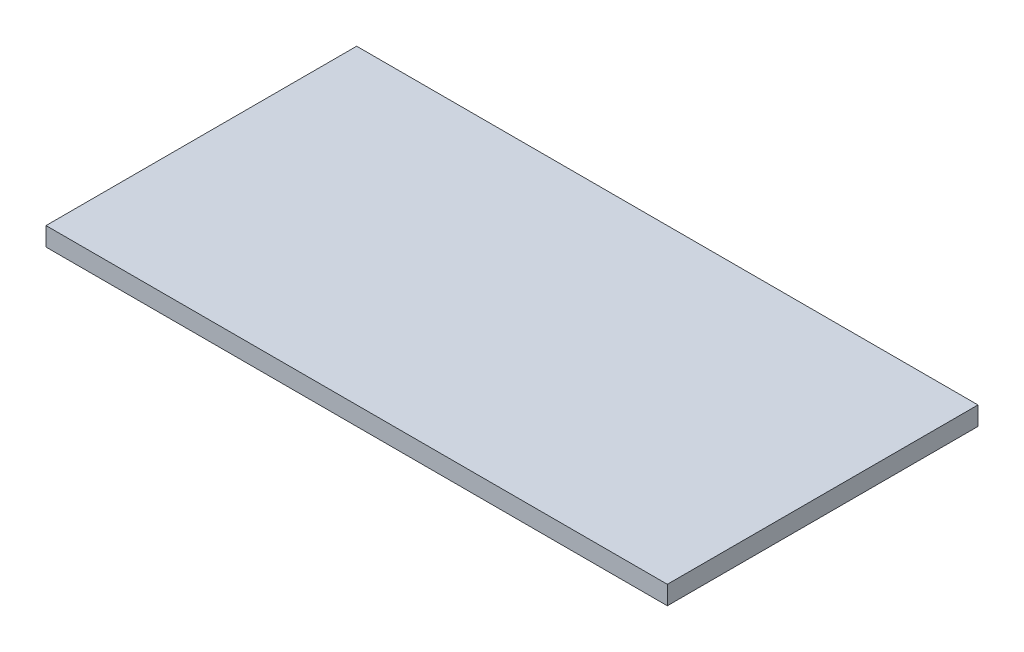
from build123d import *

# Parameters (mm, degrees)
SKETCH_1_W      = 600
SKETCH_1_H      = 300
EXTRUDE_1_DEPTH = 18


with BuildPart() as part:
    # Эскиз1 → Бобышка-Вытянуть1 (new body)
    with BuildSketch(Plane(origin=(0, 0, 0), x_dir=(1, 0, 0), z_dir=(0, 1, 0))):
        with Locations((300, 150)):
            Rectangle(SKETCH_1_W, SKETCH_1_H)
    extrude(amount=EXTRUDE_1_DEPTH)


solid = part.part
